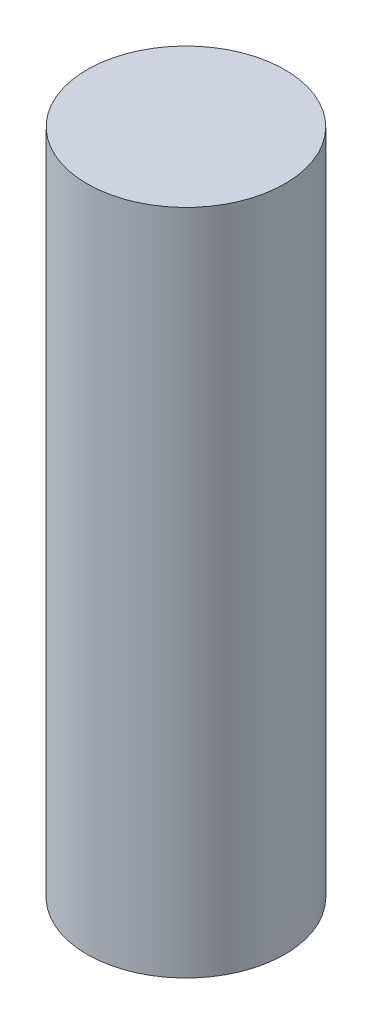
from build123d import *

# Parameters (mm, degrees)
SKETCH1_R           = 4
BOSS_EXTRUDE1_DEPTH = 13.5


with BuildPart() as part:
    # Sketch1 → Boss-Extrude1 (new body, symmetric)
    with BuildSketch(Plane(origin=(0, 0, 0), x_dir=(1, 0, 0), z_dir=(0, 1, 0))):
        Circle(SKETCH1_R)
    extrude(amount=BOSS_EXTRUDE1_DEPTH, both=True)


solid = part.part
